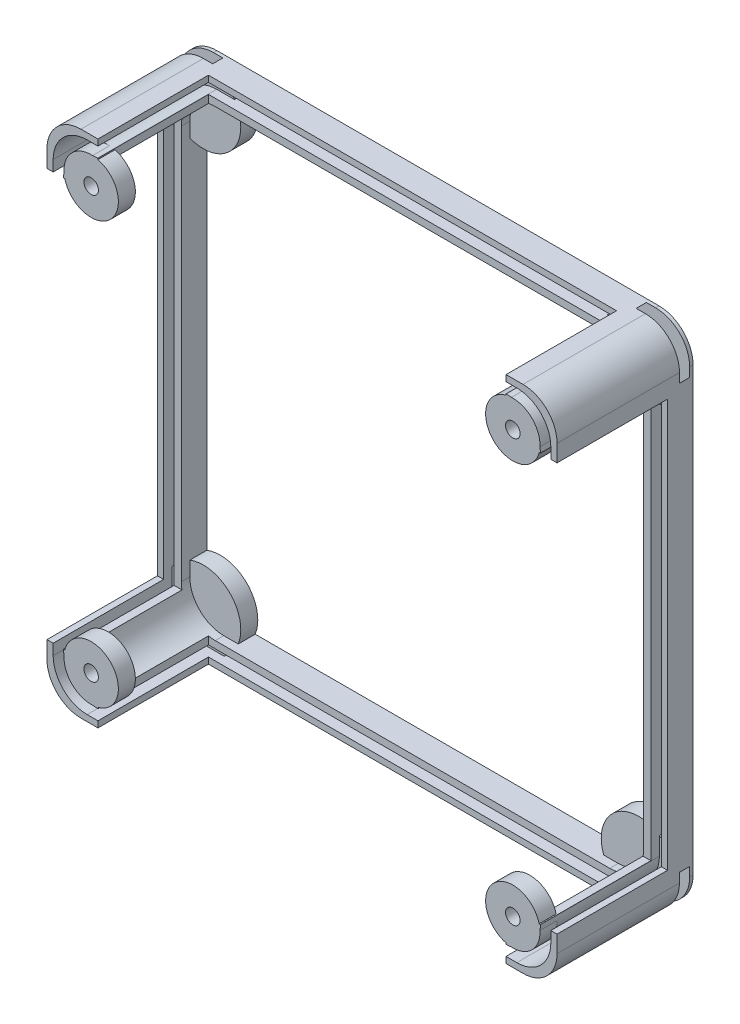
from build123d import *

# Parameters (mm, degrees)
SKETCH1_R             = 11
BOSS_EXTRUDE1_DEPTH   = 5
BOSS_EXTRUDE1_2_DEPTH = 5
BOSS_EXTRUDE1_3_DEPTH = 5
BOSS_EXTRUDE1_4_DEPTH = 5
BOSS_EXTRUDE2_START   = 1
BOSS_EXTRUDE2_DEPTH   = 3
BOSS_EXTRUDE2_2_DEPTH = 3
BOSS_EXTRUDE2_3_DEPTH = 3
BOSS_EXTRUDE2_4_DEPTH = 3
SKETCH3_W             = 150
SKETCH3_H             = 150
SKETCH3_W_2           = 146.352390556
SKETCH3_H_2           = 146.352390556
BOSS_EXTRUDE4_DEPTH   = 40
SKETCH3_W_3           = 140.198704382
SKETCH3_H_3           = 140.198704382
SKETCH3_W_4           = 136
SKETCH3_H_4           = 136
BOSS_EXTRUDE4_2_DEPTH = 40
FILLET1_R             = 10
FILLET2_R             = 10
BOSS_EXTRUDE6_START   = 40
SKETCH6_W             = 120
SKETCH6_H             = 120
SKETCH6_H_2           = 23.888569694
SKETCH6_W_2           = 20.217809466
BOSS_EXTRUDE6_DEPTH   = 32.5
SKETCH7_R             = 8
SKETCH7_R_2           = 2.14
BOSS_EXTRUDE7_DEPTH   = 5


with BuildPart() as part:
    # Sketch1 → Boss-Extrude1 (new body)
    with BuildSketch(Plane.XY):
        with Locations((-64, -64)):
            Circle(SKETCH1_R)
    extrude(amount=BOSS_EXTRUDE1_DEPTH)


with BuildPart() as body_2:
    # Sketch1 → Boss-Extrude1 2 (new body)
    with BuildSketch(Plane.XY):
        with Locations((-64, 64)):
            Circle(SKETCH1_R)
    extrude(amount=BOSS_EXTRUDE1_2_DEPTH)


with BuildPart() as body_3:
    # Sketch1 → Boss-Extrude1 3 (new body)
    with BuildSketch(Plane.XY):
        with Locations((64, -64)):
            Circle(SKETCH1_R)
    extrude(amount=BOSS_EXTRUDE1_3_DEPTH)


with BuildPart() as body_4:
    # Sketch1 → Boss-Extrude1 4 (new body)
    with BuildSketch(Plane.XY):
        with Locations((64, 64)):
            Circle(SKETCH1_R)
    extrude(amount=BOSS_EXTRUDE1_4_DEPTH)


with BuildPart() as body_5:
    # Sketch2 → Boss-Extrude2 (new body)
    with BuildSketch(Plane.XY.offset(BOSS_EXTRUDE2_START)):
        with BuildLine():
            Line((-57.636038969, -70.363961031), (-77.792434068, -90.52035613))
            ThreePointArc((-77.792434068, -90.52035613), (-90.52035613, -90.52035613), (-90.52035613, -77.792434068))
            Line((-90.52035613, -77.792434068), (-70.363961031, -57.636038969))
            ThreePointArc((-70.363961031, -57.636038969), (-57.636038969, -57.636038969), (-57.636038969, -70.363961031))
        make_face()
    extrude(amount=BOSS_EXTRUDE2_DEPTH)


with BuildPart() as body_6:
    # Sketch2 → Boss-Extrude2 2 (new body)
    with BuildSketch(Plane.XY.offset(BOSS_EXTRUDE2_START)):
        with BuildLine():
            Line((-70.363961031, 57.636038969), (-87.555608123, 74.827686061))
            ThreePointArc((-87.555608123, 74.827686061), (-87.555608123, 87.555608123), (-74.827686061, 87.555608123))
            Line((-74.827686061, 87.555608123), (-57.636038969, 70.363961031))
            ThreePointArc((-57.636038969, 70.363961031), (-57.636038969, 57.636038969), (-70.363961031, 57.636038969))
        make_face()
    extrude(amount=BOSS_EXTRUDE2_2_DEPTH)


with BuildPart() as body_7:
    # Sketch2 → Boss-Extrude2 3 (new body)
    with BuildSketch(Plane.XY.offset(BOSS_EXTRUDE2_START)):
        with BuildLine():
            Line((70.363961031, -57.636038969), (87.260513721, -74.532591659))
            ThreePointArc((87.260513721, -74.532591659), (87.260513721, -87.260513721), (74.532591659, -87.260513721))
            Line((74.532591659, -87.260513721), (57.636038969, -70.363961031))
            ThreePointArc((57.636038969, -70.363961031), (57.636038969, -57.636038969), (70.363961031, -57.636038969))
        make_face()
    extrude(amount=BOSS_EXTRUDE2_3_DEPTH)


with BuildPart() as body_8:
    # Sketch2 → Boss-Extrude2 4 (new body)
    with BuildSketch(Plane.XY.offset(BOSS_EXTRUDE2_START)):
        with BuildLine():
            Line((57.636038969, 70.363961031), (76.733324594, 89.461246655))
            ThreePointArc((76.733324594, 89.461246655), (89.461246655, 89.461246655), (89.461246655, 76.733324594))
            Line((89.461246655, 76.733324594), (70.363961031, 57.636038969))
            ThreePointArc((70.363961031, 57.636038969), (57.636038969, 57.636038969), (57.636038969, 70.363961031))
        make_face()
    extrude(amount=BOSS_EXTRUDE2_4_DEPTH)


with BuildPart() as body_9:
    # Sketch3 → Boss-Extrude4 (new body)
    with BuildSketch(Plane.XY):
        Rectangle(SKETCH3_W, SKETCH3_H)
        Rectangle(SKETCH3_W_2, SKETCH3_H_2, mode=Mode.SUBTRACT)
    extrude(amount=BOSS_EXTRUDE4_DEPTH)

    # Fillet1
    fillet1_edges = [body_9.edges().sort_by_distance(p)[0] for p in [
        (-75, -75, 20),
        (-75, 75, 20),
        (75, 75, 20),
        (75, -75, 20),
        (-73.176195278, -73.176195278, 20),
        (73.176195278, -73.176195278, 20),
        (73.176195278, 73.176195278, 20),
        (-73.176195278, 73.176195278, 20),
    ]]
    fillet(fillet1_edges, radius=FILLET1_R)


with BuildPart() as body_10:
    # Sketch3 → Boss-Extrude4 2 (new body)
    with BuildSketch(Plane.XY):
        Rectangle(SKETCH3_W_3, SKETCH3_H_3)
        Rectangle(SKETCH3_W_4, SKETCH3_H_4, mode=Mode.SUBTRACT)
    extrude(amount=BOSS_EXTRUDE4_2_DEPTH)

    # Fillet2
    fillet2_edges = [body_10.edges().sort_by_distance(p)[0] for p in [
        (70.099352191, 70.099352191, 20),
        (70.099352191, -70.099352191, 20),
        (-70.099352191, -70.099352191, 20),
        (-70.099352191, 70.099352191, 20),
        (-68, -68, 20),
        (68, -68, 20),
        (68, 68, 20),
        (-68, 68, 20),
    ]]
    fillet(fillet2_edges, radius=FILLET2_R)


with BuildPart() as part_1:
    add(part.part)

    # Combine4: union body 4, body 3, body 2, body 9, body 10
    add(body_4.part)
    add(body_3.part)
    add(body_2.part)
    add(body_9.part)
    add(body_10.part)

    # Combine8: cut body 7, body 5, body 6, body 8
    add(body_7.part, mode=Mode.SUBTRACT)
    add(body_5.part, mode=Mode.SUBTRACT)
    add(body_6.part, mode=Mode.SUBTRACT)
    add(body_8.part, mode=Mode.SUBTRACT)


with BuildPart() as body_2_2:
    # Sketch6 → Boss-Extrude6 (new body)
    with BuildSketch(Plane.XY.offset(BOSS_EXTRUDE6_START)):
        Rectangle(SKETCH6_W, SKETCH6_H)
        with Locations((0, -71.944284847)):
            Rectangle(SKETCH6_W, SKETCH6_H_2)
        with Locations((-70.108904733, 0)):
            Rectangle(SKETCH6_W_2, SKETCH6_H)
        with Locations((0, 71.944284847)):
            Rectangle(SKETCH6_W, SKETCH6_H_2)
        with Locations((70.108904733, 0)):
            Rectangle(SKETCH6_W_2, SKETCH6_H)
    extrude(amount=-BOSS_EXTRUDE6_DEPTH)


with BuildPart() as part_2:
    add(part_1.part)

    # Combine9: cut body 2 2
    add(body_2_2.part, mode=Mode.SUBTRACT)

    # Sketch7 → Boss-Extrude7 (add)
    with BuildSketch(Plane.XY.offset(40)):
        with Locations((-62, -62)):
            Circle(SKETCH7_R)
        with Locations((-62, -62)):
            Circle(SKETCH7_R_2, mode=Mode.SUBTRACT)
        with Locations((-62, 62)):
            Circle(SKETCH7_R)
        with Locations((-62, 62)):
            Circle(SKETCH7_R_2, mode=Mode.SUBTRACT)
        with Locations((62, -62)):
            Circle(SKETCH7_R)
        with Locations((62, -62)):
            Circle(SKETCH7_R_2, mode=Mode.SUBTRACT)
        with Locations((62, 62)):
            Circle(SKETCH7_R)
        with Locations((62, 62)):
            Circle(SKETCH7_R_2, mode=Mode.SUBTRACT)
    extrude(amount=-BOSS_EXTRUDE7_DEPTH)


solid = part_2.part
